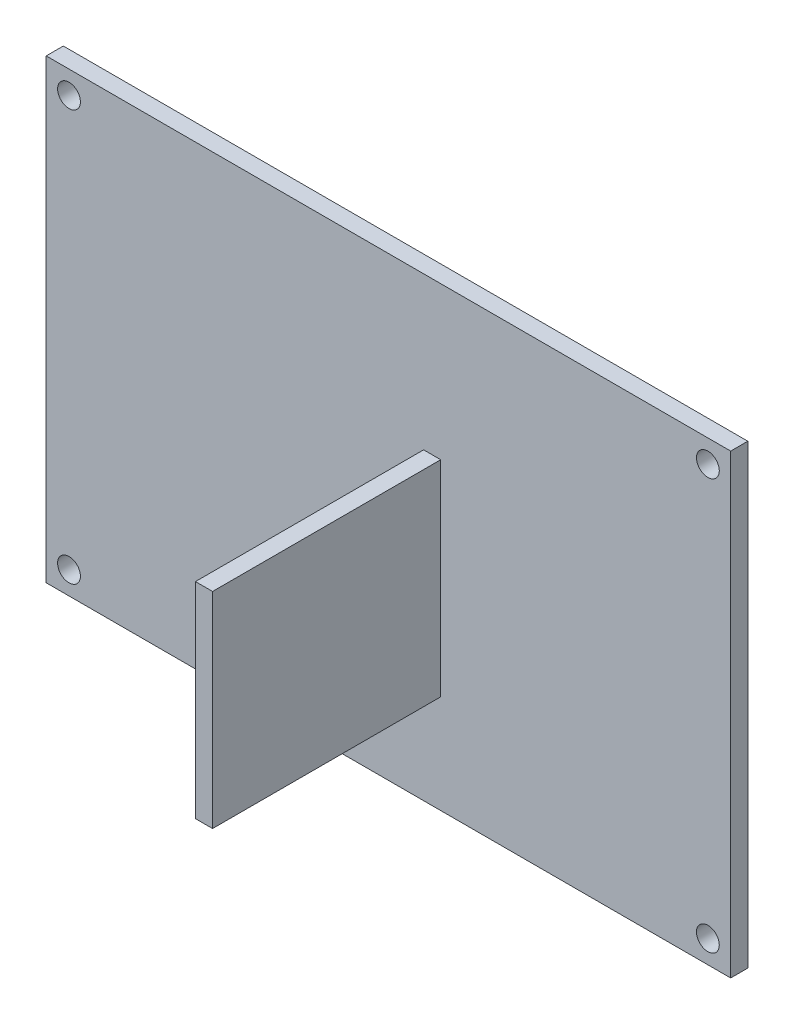
from build123d import *

# Parameters (mm, degrees)
ESBO_O1_W                = 60
ESBO_O1_H                = 40
RESSALTO_EXTRUS_O1_DEPTH = 1.5
ESBO_O2_R                = 1
CORTE_EXTRUS_O1_DEPTH    = 2.5
ESBO_O3_W                = 1.5
ESBO_O3_H                = 18
RESSALTO_EXTRUS_O2_DEPTH = 20


with BuildPart() as part:
    # Esboço1 → Ressalto-extrusão1 (new body)
    with BuildSketch(Plane.XY):
        Rectangle(ESBO_O1_W, ESBO_O1_H)
    extrude(amount=RESSALTO_EXTRUS_O1_DEPTH)

    # Esboço2 → Corte-extrusão1 (cut, through all)
    with BuildSketch(Plane.XY.offset(1.5)):
        with Locations((-28, 18)):
            Circle(ESBO_O2_R)
        with Locations((28, 18)):
            Circle(ESBO_O2_R)
        with Locations((28, -18)):
            Circle(ESBO_O2_R)
        with Locations((-28, -18)):
            Circle(ESBO_O2_R)
    extrude(amount=-CORTE_EXTRUS_O1_DEPTH, mode=Mode.SUBTRACT)

    # Esboço3 → Ressalto-extrusão2 (add)
    with BuildSketch(Plane.XY.offset(1.5)):
        with Locations((3.833169049, -2.364388559)):
            Rectangle(ESBO_O3_W, ESBO_O3_H)
    extrude(amount=RESSALTO_EXTRUS_O2_DEPTH)


solid = part.part
